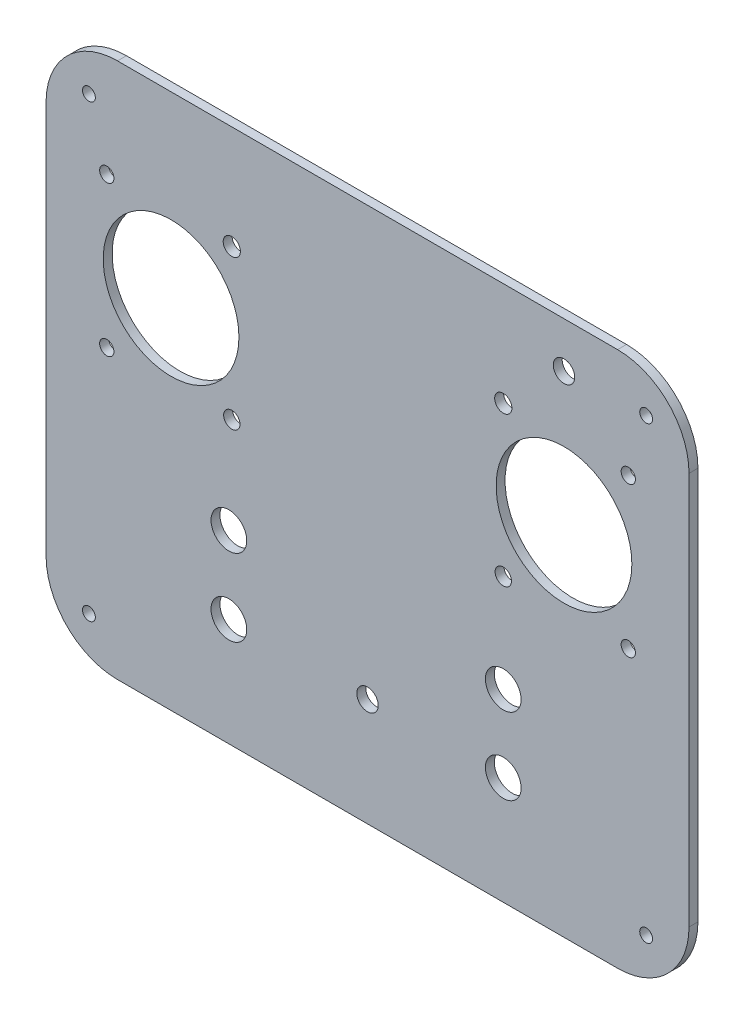
from build123d import *

# Parameters (mm, degrees)
SKETCH1_W           = 180
SKETCH1_H           = 150
SKETCH1_R           = 19
SKETCH1_R_2         = 2
SKETCH1_R_3         = 2.412227545
SKETCH1_R_4         = 2.29012976
SKETCH1_R_5         = 5
SKETCH1_R_6         = 3
BOSS_EXTRUDE3_DEPTH = 2.5
FILLET2_R           = 20
CUT_EXTRUDE1_REACH  = 4.5
SKETCH2_R           = 1.8


with BuildPart() as part:
    # Sketch1 → Boss-Extrude3 (new body)
    with BuildSketch(Plane.XY):
        with Locations((1.018867925, 17.603773585)):
            Rectangle(SKETCH1_W, SKETCH1_H)
        with Locations((-53.981132075, 42.603773585)):
            Circle(SKETCH1_R, mode=Mode.SUBTRACT)
        with Locations((-71.981132075, 63.603773585)):
            Circle(SKETCH1_R_2, mode=Mode.SUBTRACT)
        with Locations((-71.981132075, 21.603773585)):
            Circle(SKETCH1_R_2, mode=Mode.SUBTRACT)
        with Locations((-36.981132075, 63.603773585)):
            Circle(SKETCH1_R_3, mode=Mode.SUBTRACT)
        with Locations((-36.981132075, 21.603773585)):
            Circle(SKETCH1_R_4, mode=Mode.SUBTRACT)
        with Locations((39.018867925, 63.603773585)):
            Circle(SKETCH1_R_3, mode=Mode.SUBTRACT)
        with Locations((74.018867925, 63.603773585)):
            Circle(SKETCH1_R_2, mode=Mode.SUBTRACT)
        with Locations((74.018867925, 21.603773585)):
            Circle(SKETCH1_R_2, mode=Mode.SUBTRACT)
        with Locations((39.018867925, 21.603773585)):
            Circle(SKETCH1_R_4, mode=Mode.SUBTRACT)
        with Locations((56.018867925, 42.603773585)):
            Circle(SKETCH1_R, mode=Mode.SUBTRACT)
        with Locations((-37.797961742, -27.20701666)):
            Circle(SKETCH1_R_5, mode=Mode.SUBTRACT)
        with Locations((-37.797961742, -5.637572315)):
            Circle(SKETCH1_R_5, mode=Mode.SUBTRACT)
        with Locations((39.018867925, -5.760467761)):
            Circle(SKETCH1_R_5, mode=Mode.SUBTRACT)
        with Locations((1.018867925, -27.20701666)):
            Circle(SKETCH1_R_6, mode=Mode.SUBTRACT)
        with Locations((39.018867925, -27.20701666)):
            Circle(SKETCH1_R_5, mode=Mode.SUBTRACT)
        with Locations((56.018867925, 79.876860749)):
            Circle(SKETCH1_R_6, mode=Mode.SUBTRACT)
    extrude(amount=BOSS_EXTRUDE3_DEPTH)

    # Fillet2
    fillet2_edges = [part.edges().sort_by_distance(p)[0] for p in [
        (91.018867925, -57.396226415, 1.25),
        (-88.981132075, -57.396226415, 1.25),
        (-88.981132075, 92.603773585, 1.25),
        (91.018867925, 92.603773585, 1.25),
    ]]
    fillet(fillet2_edges, radius=FILLET2_R)

    # Sketch2 → Cut-Extrude1 (cut, up to next)
    with BuildSketch(Plane.XY.offset(2.5), mode=Mode.PRIVATE) as cut_extrude1_sk1:
        with Locations((-76.981132075, -45.396226415)):
            Circle(SKETCH2_R)
    cut_extrude1_tool1 = extrude(cut_extrude1_sk1.sketch, amount=-CUT_EXTRUDE1_REACH, mode=Mode.PRIVATE) & part.part
    add(cut_extrude1_tool1.solids().sort_by_distance((-76.981132, -45.396226, 2.5))[0], mode=Mode.SUBTRACT)
    # Sketch2 → Cut-Extrude1 (cut, up to next)
    with BuildSketch(Plane.XY.offset(2.5), mode=Mode.PRIVATE) as cut_extrude1_sk2:
        with Locations((79.018867925, -45.396226415)):
            Circle(SKETCH2_R)
    cut_extrude1_tool2 = extrude(cut_extrude1_sk2.sketch, amount=-CUT_EXTRUDE1_REACH, mode=Mode.PRIVATE) & part.part
    add(cut_extrude1_tool2.solids().sort_by_distance((79.018868, -45.396226, 2.5))[0], mode=Mode.SUBTRACT)
    # Sketch2 → Cut-Extrude1 (cut, up to next)
    with BuildSketch(Plane.XY.offset(2.5), mode=Mode.PRIVATE) as cut_extrude1_sk3:
        with Locations((-76.981132075, 80.603773585)):
            Circle(SKETCH2_R)
    cut_extrude1_tool3 = extrude(cut_extrude1_sk3.sketch, amount=-CUT_EXTRUDE1_REACH, mode=Mode.PRIVATE) & part.part
    add(cut_extrude1_tool3.solids().sort_by_distance((-76.981132, 80.603774, 2.5))[0], mode=Mode.SUBTRACT)
    # Sketch2 → Cut-Extrude1 (cut, up to next)
    with BuildSketch(Plane.XY.offset(2.5), mode=Mode.PRIVATE) as cut_extrude1_sk4:
        with Locations((79.018867925, 80.603773585)):
            Circle(SKETCH2_R)
    cut_extrude1_tool4 = extrude(cut_extrude1_sk4.sketch, amount=-CUT_EXTRUDE1_REACH, mode=Mode.PRIVATE) & part.part
    add(cut_extrude1_tool4.solids().sort_by_distance((79.018868, 80.603774, 2.5))[0], mode=Mode.SUBTRACT)


solid = part.part
